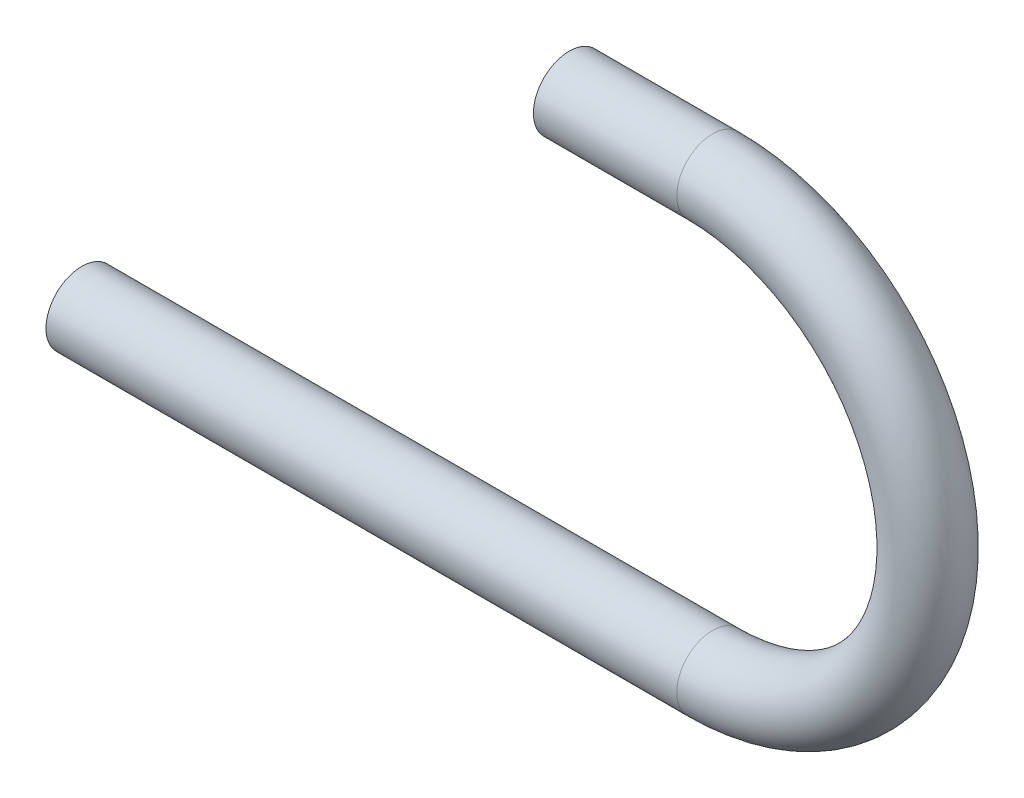
from build123d import *

# Parameters (mm, degrees)
SKETCH2_R   = 6.35
SKETCH2_R_2 = 5.588


with BuildPart() as part:
    # Sweep1: sweep along a path in Sketch1
    with BuildLine(Plane.XY) as sweep1_path:
        Line((-6.852595047, 34.461171999), (18.547404953, 34.461171999))
        ThreePointArc((18.547404953, 34.461171999), (56.647404953, -3.638828001), (18.547404953, -41.738828001))
        Line((18.547404953, -41.738828001), (-93.212595047, -41.738828001))
    # Sketch2 → Sweep1 (sweep)
    with BuildSketch(Plane(origin=(-6.852595047, 34.461171999, 0), x_dir=(0, 0, -1), z_dir=(1, 0, 0))):
        Circle(SKETCH2_R)
        Circle(SKETCH2_R_2, mode=Mode.SUBTRACT)
    sweep(path=sweep1_path.line)


solid = part.part
